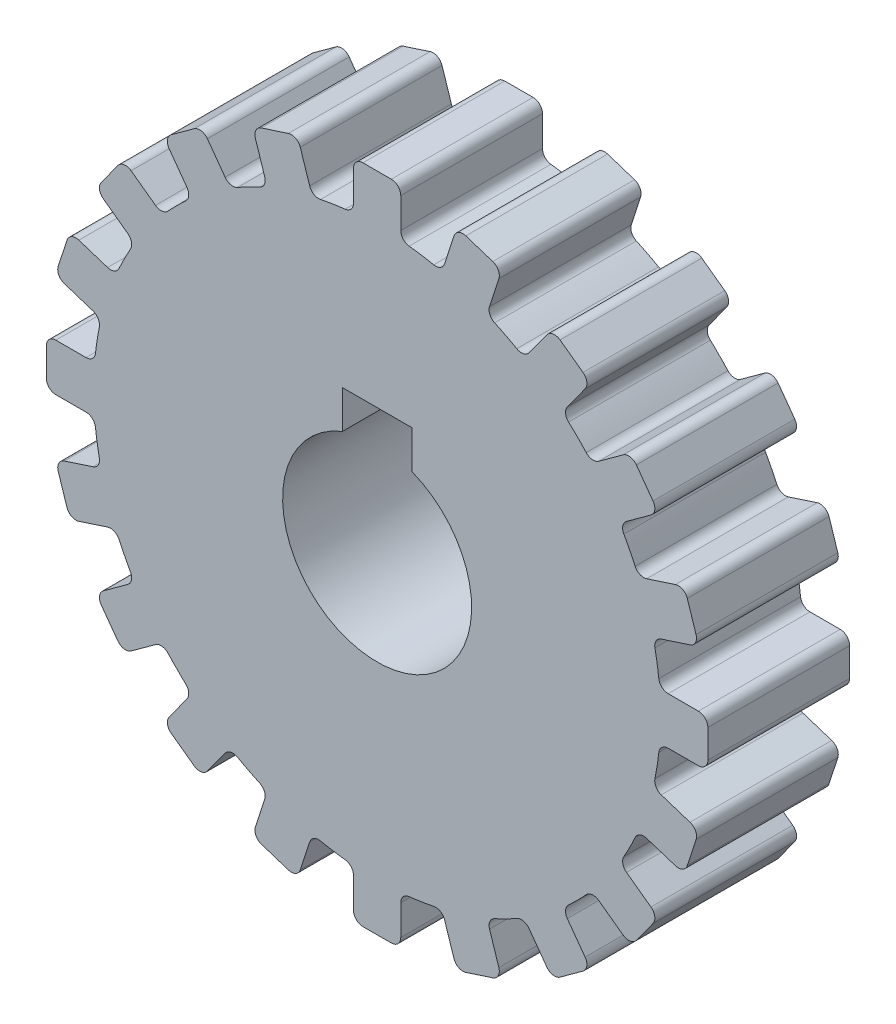
from build123d import *

# Parameters (mm, degrees)
BOSS_EXTRUDE1_DEPTH = 30
CUT_EXTRUDE1_DEPTH  = 30
SKETCH3_R           = 54.321512685
SKETCH3_R_2         = 20
CUT_EXTRUDE2_DEPTH  = 15
FILLET2_R           = 1
BOSS_EXTRUDE2_DEPTH = 15
CUT_EXTRUDE3_DEPTH  = 45
SKETCH6_R           = 95.551484503
CUT_EXTRUDE4_DEPTH  = 30


with BuildPart() as part:
    # Sketch1 → Boss-Extrude1 (new body)
    with BuildSketch(Plane.XY):
        with BuildLine():
            Line((8.324757236, 68.541581664), (7.840926028, 65.486791638))
            ThreePointArc((7.840926028, 65.486791638), (7.462274894, 64.85008445), (6.749400752, 64.648631768))
            ThreePointArc((6.749400752, 64.648631768), (5.099841222, 64.799626693), (3.446969697, 64.908538729))
            ThreePointArc((3.446969697, 64.908538729), (2.774386362, 65.219029279), (2.5, 65.907131632))
            Line((2.5, 65.907131632), (2.5, 69))
            ThreePointArc((2.5, 69), (2.207106781, 69.707106781), (1.5, 70))
            Line((1.5, 70), (-1.5, 70))
            ThreePointArc((-1.5, 70), (-2.207106781, 69.707106781), (-2.5, 69))
            Line((-2.5, 69), (-2.5, 65.907131632))
            ThreePointArc((-2.5, 65.907131632), (-2.774386362, 65.219029279), (-3.446969697, 64.908538729))
            ThreePointArc((-3.446969697, 64.908538729), (-5.099841222, 64.799626693), (-6.749400753, 64.648631768))
            ThreePointArc((-6.749400753, 64.648631768), (-7.462274894, 64.85008445), (-7.840926028, 65.486791638))
            Line((-7.840926028, 65.486791638), (-8.324757236, 68.541581664))
            ThreePointArc((-8.324757236, 68.541581664), (-8.724660325, 69.194164193), (-9.468880042, 69.372835539))
            Line((-9.468880042, 69.372835539), (-12.431945064, 68.903532144))
            ThreePointArc((-12.431945064, 68.903532144), (-13.084527593, 68.503629056), (-13.263198939, 67.759409339))
            Line((-13.263198939, 67.759409339), (-12.779367731, 64.704619313))
            ThreePointArc((-12.779367731, 64.704619313), (-12.942733018, 63.982065158), (-13.558464313, 63.570182047))
            ThreePointArc((-13.558464313, 63.570182047), (-15.173948651, 63.204044826), (-16.779578555, 62.796860937))
            ThreePointArc((-16.779578555, 62.796860937), (-17.515190176, 62.884315317), (-17.988782434, 63.453949495))
            Line((-17.988782434, 63.453949495), (-18.944531321, 66.39544211))
            ThreePointArc((-18.944531321, 66.39544211), (-19.441597338, 66.97743164), (-20.204604832, 67.037481632))
            Line((-20.204604832, 67.037481632), (-23.057774381, 66.110430649))
            ThreePointArc((-23.057774381, 66.110430649), (-23.639763911, 65.613364633), (-23.699813903, 64.850357138))
            Line((-23.699813903, 64.850357138), (-22.744065016, 61.908864523))
            ThreePointArc((-22.744065016, 61.908864523), (-22.792386632, 61.169650248), (-23.336104539, 60.666516506))
            ThreePointArc((-23.336104539, 60.666516506), (-24.874423104, 60.052169613), (-26.396587446, 59.398822978))
            ThreePointArc((-26.396587446, 59.398822978), (-27.136823346, 59.37012564), (-27.693695316, 59.858660524))
            Line((-27.693695316, 59.858660524), (-29.097828172, 62.614426418))
            ThreePointArc((-29.097828172, 62.614426418), (-29.679817701, 63.111492435), (-30.442825196, 63.051442443))
            Line((-30.442825196, 63.051442443), (-33.115844768, 61.689470944))
            ThreePointArc((-33.115844768, 61.689470944), (-33.612910785, 61.107481414), (-33.552860793, 60.34447392))
            Line((-33.552860793, 60.34447392), (-32.148727937, 57.588708026))
            ThreePointArc((-32.148727937, 57.588708026), (-32.080816044, 56.851035538), (-32.539132424, 56.269039988))
            ThreePointArc((-32.539132424, 56.269039988), (-33.962406707, 55.421610683), (-35.363624749, 54.538188865))
            ThreePointArc((-35.363624749, 54.538188865), (-36.090257863, 54.394046431), (-36.716697508, 54.789452672))
            Line((-36.716697508, 54.789452672), (-38.534639922, 57.291635743))
            ThreePointArc((-38.534639922, 57.291635743), (-39.187222452, 57.691538831), (-39.931442169, 57.512867485))
            Line((-39.931442169, 57.512867485), (-42.358493152, 55.749511728))
            ThreePointArc((-42.358493152, 55.749511728), (-42.75839624, 55.096929199), (-42.579724894, 54.352709481))
            Line((-42.579724894, 54.352709481), (-40.76178248, 51.85052641))
            ThreePointArc((-40.76178248, 51.85052641), (-40.579309295, 51.132559656), (-40.940938877, 50.486032959))
            ThreePointArc((-40.940938877, 50.486032959), (-42.214123142, 49.426387764), (-43.459892245, 48.334643539))
            ThreePointArc((-43.459892245, 48.334643539), (-44.155030455, 48.078605276), (-44.835612753, 48.371146659))
            Line((-44.835612753, 48.371146659), (-47.022600949, 50.558134855))
            ThreePointArc((-47.022600949, 50.558134855), (-47.72970773, 50.851028074), (-48.436814511, 50.558134855))
            Line((-48.436814511, 50.558134855), (-50.558134855, 48.436814511))
            ThreePointArc((-50.558134855, 48.436814511), (-50.851028074, 47.72970773), (-50.558134855, 47.022600949))
            Line((-50.558134855, 47.022600949), (-48.371146659, 44.835612753))
            ThreePointArc((-48.371146659, 44.835612753), (-48.078605276, 44.155030455), (-48.334643539, 43.459892245))
            ThreePointArc((-48.334643539, 43.459892245), (-49.426387764, 42.214123141), (-50.486032959, 40.940938877))
            ThreePointArc((-50.486032959, 40.940938877), (-51.132559656, 40.579309295), (-51.85052641, 40.76178248))
            Line((-51.85052641, 40.76178248), (-54.352709481, 42.579724894))
            ThreePointArc((-54.352709481, 42.579724894), (-55.096929199, 42.75839624), (-55.749511728, 42.358493152))
            Line((-55.749511728, 42.358493152), (-57.512867485, 39.931442169))
            ThreePointArc((-57.512867485, 39.931442169), (-57.691538831, 39.187222452), (-57.291635743, 38.534639922))
            Line((-57.291635743, 38.534639922), (-54.789452672, 36.716697508))
            ThreePointArc((-54.789452672, 36.716697508), (-54.394046431, 36.090257863), (-54.538188865, 35.363624749))
            ThreePointArc((-54.538188865, 35.363624749), (-55.421610683, 33.962406707), (-56.269039988, 32.539132424))
            ThreePointArc((-56.269039988, 32.539132424), (-56.851035538, 32.080816044), (-57.588708026, 32.148727937))
            Line((-57.588708026, 32.148727937), (-60.34447392, 33.552860793))
            ThreePointArc((-60.34447392, 33.552860793), (-61.107481414, 33.612910785), (-61.689470944, 33.115844768))
            Line((-61.689470944, 33.115844768), (-63.051442443, 30.442825196))
            ThreePointArc((-63.051442443, 30.442825196), (-63.111492435, 29.679817701), (-62.614426418, 29.097828172))
            Line((-62.614426418, 29.097828172), (-59.858660524, 27.693695316))
            ThreePointArc((-59.858660524, 27.693695316), (-59.37012564, 27.136823346), (-59.398822978, 26.396587446))
            ThreePointArc((-59.398822978, 26.396587446), (-60.052169613, 24.874423104), (-60.666516506, 23.336104539))
            ThreePointArc((-60.666516506, 23.336104539), (-61.169650248, 22.792386632), (-61.908864523, 22.744065016))
            Line((-61.908864523, 22.744065016), (-64.850357138, 23.699813903))
            ThreePointArc((-64.850357138, 23.699813903), (-65.613364633, 23.639763911), (-66.110430649, 23.057774381))
            Line((-66.110430649, 23.057774381), (-67.037481632, 20.204604832))
            ThreePointArc((-67.037481632, 20.204604832), (-66.97743164, 19.441597338), (-66.39544211, 18.944531321))
            Line((-66.39544211, 18.944531321), (-63.453949495, 17.988782434))
            ThreePointArc((-63.453949495, 17.988782434), (-62.884315317, 17.515190176), (-62.796860937, 16.779578555))
            ThreePointArc((-62.796860937, 16.779578555), (-63.204044826, 15.173948651), (-63.570182047, 13.558464313))
            ThreePointArc((-63.570182047, 13.558464313), (-63.982065158, 12.942733018), (-64.704619313, 12.779367731))
            Line((-64.704619313, 12.779367731), (-67.759409339, 13.263198939))
            ThreePointArc((-67.759409339, 13.263198939), (-68.503629056, 13.084527593), (-68.903532144, 12.431945064))
            Line((-68.903532144, 12.431945064), (-69.372835539, 9.468880042))
            ThreePointArc((-69.372835539, 9.468880042), (-69.194164193, 8.724660325), (-68.541581664, 8.324757236))
            Line((-68.541581664, 8.324757236), (-65.486791638, 7.840926028))
            ThreePointArc((-65.486791638, 7.840926028), (-64.85008445, 7.462274894), (-64.648631768, 6.749400752))
            ThreePointArc((-64.648631768, 6.749400752), (-64.799626693, 5.099841222), (-64.908538729, 3.446969697))
            ThreePointArc((-64.908538729, 3.446969697), (-65.219029279, 2.774386362), (-65.907131632, 2.5))
            Line((-65.907131632, 2.5), (-69, 2.5))
            ThreePointArc((-69, 2.5), (-69.707106781, 2.207106781), (-70, 1.5))
            Line((-70, 1.5), (-70, -1.5))
            ThreePointArc((-70, -1.5), (-69.707106781, -2.207106781), (-69, -2.5))
            Line((-69, -2.5), (-65.907131632, -2.5))
            ThreePointArc((-65.907131632, -2.5), (-65.219029279, -2.774386362), (-64.908538729, -3.446969697))
            ThreePointArc((-64.908538729, -3.446969697), (-64.799626693, -5.099841222), (-64.648631768, -6.749400753))
            ThreePointArc((-64.648631768, -6.749400753), (-64.85008445, -7.462274894), (-65.486791638, -7.840926028))
            Line((-65.486791638, -7.840926028), (-68.541581664, -8.324757236))
            ThreePointArc((-68.541581664, -8.324757236), (-69.194164193, -8.724660325), (-69.372835539, -9.468880042))
            Line((-69.372835539, -9.468880042), (-68.903532144, -12.431945064))
            ThreePointArc((-68.903532144, -12.431945064), (-68.503629056, -13.084527593), (-67.759409339, -13.263198939))
            Line((-67.759409339, -13.263198939), (-64.704619313, -12.779367731))
            ThreePointArc((-64.704619313, -12.779367731), (-63.982065158, -12.942733018), (-63.570182047, -13.558464313))
            ThreePointArc((-63.570182047, -13.558464313), (-63.204044826, -15.173948651), (-62.796860937, -16.779578555))
            ThreePointArc((-62.796860937, -16.779578555), (-62.884315317, -17.515190176), (-63.453949495, -17.988782434))
            Line((-63.453949495, -17.988782434), (-66.39544211, -18.944531321))
            ThreePointArc((-66.39544211, -18.944531321), (-66.97743164, -19.441597338), (-67.037481632, -20.204604832))
            Line((-67.037481632, -20.204604832), (-66.110430649, -23.057774381))
            ThreePointArc((-66.110430649, -23.057774381), (-65.613364633, -23.639763911), (-64.850357138, -23.699813903))
            Line((-64.850357138, -23.699813903), (-61.908864523, -22.744065016))
            ThreePointArc((-61.908864523, -22.744065016), (-61.169650248, -22.792386632), (-60.666516506, -23.336104539))
            ThreePointArc((-60.666516506, -23.336104539), (-60.052169613, -24.874423104), (-59.398822978, -26.396587446))
            ThreePointArc((-59.398822978, -26.396587446), (-59.37012564, -27.136823346), (-59.858660524, -27.693695316))
            Line((-59.858660524, -27.693695316), (-62.614426418, -29.097828172))
            ThreePointArc((-62.614426418, -29.097828172), (-63.111492435, -29.679817701), (-63.051442443, -30.442825196))
            Line((-63.051442443, -30.442825196), (-61.689470944, -33.115844768))
            ThreePointArc((-61.689470944, -33.115844768), (-61.107481414, -33.612910785), (-60.34447392, -33.552860793))
            Line((-60.34447392, -33.552860793), (-57.588708026, -32.148727937))
            ThreePointArc((-57.588708026, -32.148727937), (-56.851035538, -32.080816044), (-56.269039988, -32.539132424))
            ThreePointArc((-56.269039988, -32.539132424), (-55.421610683, -33.962406707), (-54.538188865, -35.363624749))
            ThreePointArc((-54.538188865, -35.363624749), (-54.394046431, -36.090257863), (-54.789452672, -36.716697508))
            Line((-54.789452672, -36.716697508), (-57.291635743, -38.534639922))
            ThreePointArc((-57.291635743, -38.534639922), (-57.691538831, -39.187222452), (-57.512867485, -39.931442169))
            Line((-57.512867485, -39.931442169), (-55.749511728, -42.358493152))
            ThreePointArc((-55.749511728, -42.358493152), (-55.096929199, -42.75839624), (-54.352709481, -42.579724894))
            Line((-54.352709481, -42.579724894), (-51.85052641, -40.76178248))
            ThreePointArc((-51.85052641, -40.76178248), (-51.132559656, -40.579309295), (-50.486032959, -40.940938877))
            ThreePointArc((-50.486032959, -40.940938877), (-49.426387764, -42.214123142), (-48.334643539, -43.459892245))
            ThreePointArc((-48.334643539, -43.459892245), (-48.078605276, -44.155030455), (-48.371146659, -44.835612753))
            Line((-48.371146659, -44.835612753), (-50.558134855, -47.022600949))
            ThreePointArc((-50.558134855, -47.022600949), (-50.851028074, -47.72970773), (-50.558134855, -48.436814511))
            Line((-50.558134855, -48.436814511), (-48.436814511, -50.558134855))
            ThreePointArc((-48.436814511, -50.558134855), (-47.72970773, -50.851028074), (-47.022600949, -50.558134855))
            Line((-47.022600949, -50.558134855), (-44.835612753, -48.371146659))
            ThreePointArc((-44.835612753, -48.371146659), (-44.155030455, -48.078605276), (-43.459892245, -48.334643539))
            ThreePointArc((-43.459892245, -48.334643539), (-42.214123141, -49.426387764), (-40.940938877, -50.486032959))
            ThreePointArc((-40.940938877, -50.486032959), (-40.579309295, -51.132559656), (-40.76178248, -51.85052641))
            Line((-40.76178248, -51.85052641), (-42.579724894, -54.352709481))
            ThreePointArc((-42.579724894, -54.352709481), (-42.75839624, -55.096929199), (-42.358493152, -55.749511728))
            Line((-42.358493152, -55.749511728), (-39.931442169, -57.512867485))
            ThreePointArc((-39.931442169, -57.512867485), (-39.187222452, -57.691538831), (-38.534639922, -57.291635743))
            Line((-38.534639922, -57.291635743), (-36.716697508, -54.789452672))
            ThreePointArc((-36.716697508, -54.789452672), (-36.090257863, -54.394046431), (-35.363624749, -54.538188865))
            ThreePointArc((-35.363624749, -54.538188865), (-33.962406707, -55.421610683), (-32.539132424, -56.269039988))
            ThreePointArc((-32.539132424, -56.269039988), (-32.080816044, -56.851035538), (-32.148727937, -57.588708026))
            Line((-32.148727937, -57.588708026), (-33.552860793, -60.34447392))
            ThreePointArc((-33.552860793, -60.34447392), (-33.612910785, -61.107481414), (-33.115844768, -61.689470944))
            Line((-33.115844768, -61.689470944), (-30.442825196, -63.051442443))
            ThreePointArc((-30.442825196, -63.051442443), (-29.679817701, -63.111492435), (-29.097828172, -62.614426418))
            Line((-29.097828172, -62.614426418), (-27.693695316, -59.858660524))
            ThreePointArc((-27.693695316, -59.858660524), (-27.136823346, -59.37012564), (-26.396587446, -59.398822978))
            ThreePointArc((-26.396587446, -59.398822978), (-24.874423104, -60.052169613), (-23.336104539, -60.666516506))
            ThreePointArc((-23.336104539, -60.666516506), (-22.792386632, -61.169650248), (-22.744065016, -61.908864523))
            Line((-22.744065016, -61.908864523), (-23.699813903, -64.850357138))
            ThreePointArc((-23.699813903, -64.850357138), (-23.639763911, -65.613364633), (-23.057774381, -66.110430649))
            Line((-23.057774381, -66.110430649), (-20.204604832, -67.037481632))
            ThreePointArc((-20.204604832, -67.037481632), (-19.441597338, -66.97743164), (-18.944531321, -66.39544211))
            Line((-18.944531321, -66.39544211), (-17.988782434, -63.453949495))
            ThreePointArc((-17.988782434, -63.453949495), (-17.515190176, -62.884315317), (-16.779578555, -62.796860937))
            ThreePointArc((-16.779578555, -62.796860937), (-15.173948651, -63.204044826), (-13.558464313, -63.570182047))
            ThreePointArc((-13.558464313, -63.570182047), (-12.942733018, -63.982065158), (-12.779367731, -64.704619313))
            Line((-12.779367731, -64.704619313), (-13.263198939, -67.759409339))
            ThreePointArc((-13.263198939, -67.759409339), (-13.084527593, -68.503629056), (-12.431945064, -68.903532144))
            Line((-12.431945064, -68.903532144), (-9.468880042, -69.372835539))
            ThreePointArc((-9.468880042, -69.372835539), (-8.724660325, -69.194164193), (-8.324757236, -68.541581664))
            Line((-8.324757236, -68.541581664), (-7.840926028, -65.486791638))
            ThreePointArc((-7.840926028, -65.486791638), (-7.462274894, -64.85008445), (-6.749400752, -64.648631768))
            ThreePointArc((-6.749400752, -64.648631768), (-5.099841222, -64.799626693), (-3.446969697, -64.908538729))
            ThreePointArc((-3.446969697, -64.908538729), (-2.774386362, -65.219029279), (-2.5, -65.907131632))
            Line((-2.5, -65.907131632), (-2.5, -69))
            ThreePointArc((-2.5, -69), (-2.207106781, -69.707106781), (-1.5, -70))
            Line((-1.5, -70), (1.5, -70))
            ThreePointArc((1.5, -70), (2.207106781, -69.707106781), (2.5, -69))
            Line((2.5, -69), (2.5, -65.907131632))
            ThreePointArc((2.5, -65.907131632), (2.774386362, -65.219029279), (3.446969697, -64.908538729))
            ThreePointArc((3.446969697, -64.908538729), (5.099841222, -64.799626693), (6.749400753, -64.648631768))
            ThreePointArc((6.749400753, -64.648631768), (7.462274894, -64.85008445), (7.840926028, -65.486791638))
            Line((7.840926028, -65.486791638), (8.324757236, -68.541581664))
            ThreePointArc((8.324757236, -68.541581664), (8.724660325, -69.194164193), (9.468880042, -69.372835539))
            Line((9.468880042, -69.372835539), (12.431945064, -68.903532144))
            ThreePointArc((12.431945064, -68.903532144), (13.084527593, -68.503629056), (13.263198939, -67.759409339))
            Line((13.263198939, -67.759409339), (12.779367731, -64.704619313))
            ThreePointArc((12.779367731, -64.704619313), (12.942733018, -63.982065158), (13.558464313, -63.570182047))
            ThreePointArc((13.558464313, -63.570182047), (15.173948651, -63.204044826), (16.779578555, -62.796860937))
            ThreePointArc((16.779578555, -62.796860937), (17.515190176, -62.884315317), (17.988782434, -63.453949495))
            Line((17.988782434, -63.453949495), (18.944531321, -66.39544211))
            ThreePointArc((18.944531321, -66.39544211), (19.441597338, -66.97743164), (20.204604832, -67.037481632))
            Line((20.204604832, -67.037481632), (23.057774381, -66.110430649))
            ThreePointArc((23.057774381, -66.110430649), (23.639763911, -65.613364633), (23.699813903, -64.850357138))
            Line((23.699813903, -64.850357138), (22.744065016, -61.908864523))
            ThreePointArc((22.744065016, -61.908864523), (22.792386632, -61.169650248), (23.336104539, -60.666516506))
            ThreePointArc((23.336104539, -60.666516506), (24.874423104, -60.052169613), (26.396587446, -59.398822978))
            ThreePointArc((26.396587446, -59.398822978), (27.136823346, -59.37012564), (27.693695316, -59.858660524))
            Line((27.693695316, -59.858660524), (29.097828172, -62.614426418))
            ThreePointArc((29.097828172, -62.614426418), (29.679817701, -63.111492435), (30.442825196, -63.051442443))
            Line((30.442825196, -63.051442443), (33.115844768, -61.689470944))
            ThreePointArc((33.115844768, -61.689470944), (33.612910785, -61.107481414), (33.552860793, -60.34447392))
            Line((33.552860793, -60.34447392), (32.148727937, -57.588708026))
            ThreePointArc((32.148727937, -57.588708026), (32.080816044, -56.851035538), (32.539132424, -56.269039988))
            ThreePointArc((32.539132424, -56.269039988), (33.962406707, -55.421610683), (35.363624749, -54.538188865))
            ThreePointArc((35.363624749, -54.538188865), (36.090257863, -54.394046431), (36.716697508, -54.789452672))
            Line((36.716697508, -54.789452672), (38.534639922, -57.291635743))
            ThreePointArc((38.534639922, -57.291635743), (39.187222452, -57.691538831), (39.931442169, -57.512867485))
            Line((39.931442169, -57.512867485), (42.358493152, -55.749511728))
            ThreePointArc((42.358493152, -55.749511728), (42.75839624, -55.096929199), (42.579724894, -54.352709481))
            Line((42.579724894, -54.352709481), (40.76178248, -51.85052641))
            ThreePointArc((40.76178248, -51.85052641), (40.579309295, -51.132559656), (40.940938877, -50.486032959))
            ThreePointArc((40.940938877, -50.486032959), (42.214123142, -49.426387764), (43.459892245, -48.334643539))
            ThreePointArc((43.459892245, -48.334643539), (44.155030455, -48.078605276), (44.835612753, -48.371146659))
            Line((44.835612753, -48.371146659), (47.022600949, -50.558134855))
            ThreePointArc((47.022600949, -50.558134855), (47.72970773, -50.851028074), (48.436814511, -50.558134855))
            Line((48.436814511, -50.558134855), (50.558134855, -48.436814511))
            ThreePointArc((50.558134855, -48.436814511), (50.851028074, -47.72970773), (50.558134855, -47.022600949))
            Line((50.558134855, -47.022600949), (48.371146659, -44.835612753))
            ThreePointArc((48.371146659, -44.835612753), (48.078605276, -44.155030455), (48.334643539, -43.459892245))
            ThreePointArc((48.334643539, -43.459892245), (49.426387764, -42.214123141), (50.486032959, -40.940938877))
            ThreePointArc((50.486032959, -40.940938877), (51.132559656, -40.579309295), (51.85052641, -40.76178248))
            Line((51.85052641, -40.76178248), (54.352709481, -42.579724894))
            ThreePointArc((54.352709481, -42.579724894), (55.096929199, -42.75839624), (55.749511728, -42.358493152))
            Line((55.749511728, -42.358493152), (57.512867485, -39.931442169))
            ThreePointArc((57.512867485, -39.931442169), (57.691538831, -39.187222452), (57.291635743, -38.534639922))
            Line((57.291635743, -38.534639922), (54.789452672, -36.716697508))
            ThreePointArc((54.789452672, -36.716697508), (54.394046431, -36.090257863), (54.538188865, -35.363624749))
            ThreePointArc((54.538188865, -35.363624749), (55.421610683, -33.962406707), (56.269039988, -32.539132424))
            ThreePointArc((56.269039988, -32.539132424), (56.851035538, -32.080816044), (57.588708026, -32.148727937))
            Line((57.588708026, -32.148727937), (60.34447392, -33.552860793))
            ThreePointArc((60.34447392, -33.552860793), (61.107481414, -33.612910785), (61.689470944, -33.115844768))
            Line((61.689470944, -33.115844768), (63.051442443, -30.442825196))
            ThreePointArc((63.051442443, -30.442825196), (63.111492435, -29.679817701), (62.614426418, -29.097828172))
            Line((62.614426418, -29.097828172), (59.858660524, -27.693695316))
            ThreePointArc((59.858660524, -27.693695316), (59.37012564, -27.136823346), (59.398822978, -26.396587446))
            ThreePointArc((59.398822978, -26.396587446), (60.052169613, -24.874423104), (60.666516506, -23.336104539))
            ThreePointArc((60.666516506, -23.336104539), (61.169650248, -22.792386632), (61.908864523, -22.744065016))
            Line((61.908864523, -22.744065016), (64.850357138, -23.699813903))
            ThreePointArc((64.850357138, -23.699813903), (65.613364633, -23.639763911), (66.110430649, -23.057774381))
            Line((66.110430649, -23.057774381), (67.037481632, -20.204604832))
            ThreePointArc((67.037481632, -20.204604832), (66.97743164, -19.441597338), (66.39544211, -18.944531321))
            Line((66.39544211, -18.944531321), (63.453949495, -17.988782434))
            ThreePointArc((63.453949495, -17.988782434), (62.884315317, -17.515190176), (62.796860937, -16.779578555))
            ThreePointArc((62.796860937, -16.779578555), (63.204044826, -15.173948651), (63.570182047, -13.558464313))
            ThreePointArc((63.570182047, -13.558464313), (63.982065158, -12.942733018), (64.704619313, -12.779367731))
            Line((64.704619313, -12.779367731), (67.759409339, -13.263198939))
            ThreePointArc((67.759409339, -13.263198939), (68.503629056, -13.084527593), (68.903532144, -12.431945064))
            Line((68.903532144, -12.431945064), (69.372835539, -9.468880042))
            ThreePointArc((69.372835539, -9.468880042), (69.194164193, -8.724660325), (68.541581664, -8.324757236))
            Line((68.541581664, -8.324757236), (65.486791638, -7.840926028))
            ThreePointArc((65.486791638, -7.840926028), (64.85008445, -7.462274894), (64.648631768, -6.749400752))
            ThreePointArc((64.648631768, -6.749400752), (64.799626693, -5.099841222), (64.908538729, -3.446969697))
            ThreePointArc((64.908538729, -3.446969697), (65.219029279, -2.774386362), (65.907131632, -2.5))
            Line((65.907131632, -2.5), (69, -2.5))
            ThreePointArc((69, -2.5), (69.707106781, -2.207106781), (70, -1.5))
            Line((70, -1.5), (70, 1.5))
            ThreePointArc((70, 1.5), (69.707106781, 2.207106781), (69, 2.5))
            Line((69, 2.5), (65.907131632, 2.5))
            ThreePointArc((65.907131632, 2.5), (65.219029279, 2.774386362), (64.908538729, 3.446969697))
            ThreePointArc((64.908538729, 3.446969697), (64.799626693, 5.099841222), (64.648631768, 6.749400753))
            ThreePointArc((64.648631768, 6.749400753), (64.85008445, 7.462274894), (65.486791638, 7.840926028))
            Line((65.486791638, 7.840926028), (68.541581664, 8.324757236))
            ThreePointArc((68.541581664, 8.324757236), (69.194164193, 8.724660325), (69.372835539, 9.468880042))
            Line((69.372835539, 9.468880042), (68.903532144, 12.431945064))
            ThreePointArc((68.903532144, 12.431945064), (68.503629056, 13.084527593), (67.759409339, 13.263198939))
            Line((67.759409339, 13.263198939), (64.704619313, 12.779367731))
            ThreePointArc((64.704619313, 12.779367731), (63.982065158, 12.942733018), (63.570182047, 13.558464313))
            ThreePointArc((63.570182047, 13.558464313), (63.204044826, 15.173948651), (62.796860937, 16.779578555))
            ThreePointArc((62.796860937, 16.779578555), (62.884315317, 17.515190176), (63.453949495, 17.988782434))
            Line((63.453949495, 17.988782434), (66.39544211, 18.944531321))
            ThreePointArc((66.39544211, 18.944531321), (66.97743164, 19.441597338), (67.037481632, 20.204604832))
            Line((67.037481632, 20.204604832), (66.110430649, 23.057774381))
            ThreePointArc((66.110430649, 23.057774381), (65.613364633, 23.639763911), (64.850357138, 23.699813903))
            Line((64.850357138, 23.699813903), (61.908864523, 22.744065016))
            ThreePointArc((61.908864523, 22.744065016), (61.169650248, 22.792386632), (60.666516506, 23.336104539))
            ThreePointArc((60.666516506, 23.336104539), (60.052169613, 24.874423104), (59.398822978, 26.396587446))
            ThreePointArc((59.398822978, 26.396587446), (59.37012564, 27.136823346), (59.858660524, 27.693695316))
            Line((59.858660524, 27.693695316), (62.614426418, 29.097828172))
            ThreePointArc((62.614426418, 29.097828172), (63.111492435, 29.679817701), (63.051442443, 30.442825196))
            Line((63.051442443, 30.442825196), (61.689470944, 33.115844768))
            ThreePointArc((61.689470944, 33.115844768), (61.107481414, 33.612910785), (60.34447392, 33.552860793))
            Line((60.34447392, 33.552860793), (57.588708026, 32.148727937))
            ThreePointArc((57.588708026, 32.148727937), (56.851035538, 32.080816044), (56.269039988, 32.539132424))
            ThreePointArc((56.269039988, 32.539132424), (55.421610683, 33.962406707), (54.538188865, 35.363624749))
            ThreePointArc((54.538188865, 35.363624749), (54.394046431, 36.090257863), (54.789452672, 36.716697508))
            Line((54.789452672, 36.716697508), (57.291635743, 38.534639922))
            ThreePointArc((57.291635743, 38.534639922), (57.691538831, 39.187222452), (57.512867485, 39.931442169))
            Line((57.512867485, 39.931442169), (55.749511728, 42.358493152))
            ThreePointArc((55.749511728, 42.358493152), (55.096929199, 42.75839624), (54.352709481, 42.579724894))
            Line((54.352709481, 42.579724894), (51.85052641, 40.76178248))
            ThreePointArc((51.85052641, 40.76178248), (51.132559656, 40.579309295), (50.486032959, 40.940938877))
            ThreePointArc((50.486032959, 40.940938877), (49.426387764, 42.214123142), (48.334643539, 43.459892245))
            ThreePointArc((48.334643539, 43.459892245), (48.078605276, 44.155030455), (48.371146659, 44.835612753))
            Line((48.371146659, 44.835612753), (50.558134855, 47.022600949))
            ThreePointArc((50.558134855, 47.022600949), (50.851028074, 47.72970773), (50.558134855, 48.436814511))
            Line((50.558134855, 48.436814511), (48.436814511, 50.558134855))
            ThreePointArc((48.436814511, 50.558134855), (47.72970773, 50.851028074), (47.022600949, 50.558134855))
            Line((47.022600949, 50.558134855), (44.835612753, 48.371146659))
            ThreePointArc((44.835612753, 48.371146659), (44.155030455, 48.078605276), (43.459892245, 48.334643539))
            ThreePointArc((43.459892245, 48.334643539), (42.214123141, 49.426387764), (40.940938877, 50.486032959))
            ThreePointArc((40.940938877, 50.486032959), (40.579309295, 51.132559656), (40.76178248, 51.85052641))
            Line((40.76178248, 51.85052641), (42.579724894, 54.352709481))
            ThreePointArc((42.579724894, 54.352709481), (42.75839624, 55.096929199), (42.358493152, 55.749511728))
            Line((42.358493152, 55.749511728), (39.931442169, 57.512867485))
            ThreePointArc((39.931442169, 57.512867485), (39.187222452, 57.691538831), (38.534639922, 57.291635743))
            Line((38.534639922, 57.291635743), (36.716697508, 54.789452672))
            ThreePointArc((36.716697508, 54.789452672), (36.090257863, 54.394046431), (35.363624749, 54.538188865))
            ThreePointArc((35.363624749, 54.538188865), (33.962406707, 55.421610683), (32.539132424, 56.269039988))
            ThreePointArc((32.539132424, 56.269039988), (32.080816044, 56.851035538), (32.148727937, 57.588708026))
            Line((32.148727937, 57.588708026), (33.552860793, 60.34447392))
            ThreePointArc((33.552860793, 60.34447392), (33.612910785, 61.107481414), (33.115844768, 61.689470944))
            Line((33.115844768, 61.689470944), (30.442825196, 63.051442443))
            ThreePointArc((30.442825196, 63.051442443), (29.679817701, 63.111492435), (29.097828172, 62.614426418))
            Line((29.097828172, 62.614426418), (27.693695316, 59.858660524))
            ThreePointArc((27.693695316, 59.858660524), (27.136823346, 59.37012564), (26.396587446, 59.398822978))
            ThreePointArc((26.396587446, 59.398822978), (24.874423104, 60.052169613), (23.336104539, 60.666516506))
            ThreePointArc((23.336104539, 60.666516506), (22.792386632, 61.169650248), (22.744065016, 61.908864523))
            Line((22.744065016, 61.908864523), (23.699813903, 64.850357138))
            ThreePointArc((23.699813903, 64.850357138), (23.639763911, 65.613364633), (23.057774381, 66.110430649))
            Line((23.057774381, 66.110430649), (20.204604832, 67.037481632))
            ThreePointArc((20.204604832, 67.037481632), (19.441597338, 66.97743164), (18.944531321, 66.39544211))
            Line((18.944531321, 66.39544211), (17.988782434, 63.453949495))
            ThreePointArc((17.988782434, 63.453949495), (17.515190176, 62.884315317), (16.779578555, 62.796860937))
            ThreePointArc((16.779578555, 62.796860937), (15.173948651, 63.204044826), (13.558464313, 63.570182047))
            ThreePointArc((13.558464313, 63.570182047), (12.942733018, 63.982065158), (12.779367731, 64.704619313))
            Line((12.779367731, 64.704619313), (13.263198939, 67.759409339))
            ThreePointArc((13.263198939, 67.759409339), (13.084527593, 68.503629056), (12.431945064, 68.903532144))
            Line((12.431945064, 68.903532144), (9.468880042, 69.372835539))
            ThreePointArc((9.468880042, 69.372835539), (8.724660325, 69.194164193), (8.324757236, 68.541581664))
        make_face()
    extrude(amount=BOSS_EXTRUDE1_DEPTH)

    # Sketch2 → Cut-Extrude1 (cut)
    with BuildSketch(Plane.XY.offset(30)):
        with BuildLine():
            Line((-3.538659763, 13.11467819), (3.538659763, 13.11467819))
            Line((3.538659763, 13.11467819), (3.538659763, 9.352961407))
            ThreePointArc((3.538659763, 9.352961407), (0, -10), (-3.538659763, 9.352961407))
            Line((-3.538659763, 9.352961407), (-3.538659763, 13.11467819))
        make_face()
    extrude(amount=-CUT_EXTRUDE1_DEPTH, mode=Mode.SUBTRACT)

    # Sketch3 → Cut-Extrude2 (cut)
    with BuildSketch(Plane.XY.offset(30)):
        Circle(SKETCH3_R)
        Circle(SKETCH3_R_2, mode=Mode.SUBTRACT)
    extrude(amount=-CUT_EXTRUDE2_DEPTH, mode=Mode.SUBTRACT)

    # Fillet2
    fillet2_edges = [part.edges().sort_by_distance(p)[0] for p in [
        (-54.321512685, 0, 30),
    ]]
    fillet(fillet2_edges, radius=FILLET2_R)

    # Sketch4 → Boss-Extrude2 (add)
    with BuildSketch(Plane.XY.offset(30)):
        with BuildLine():
            Line((8.128936518, 33.10846404), (7.140633936, 30.066781454))
            ThreePointArc((7.140633936, 30.066781454), (6.693220985, 29.511886902), (5.989913632, 29.395933982))
            ThreePointArc((5.989913632, 29.395933982), (4.693033951, 29.630650218), (3.387096774, 29.808179673))
            ThreePointArc((3.387096774, 29.808179673), (2.754043156, 30.135791378), (2.5, 30.801785663))
            Line((2.5, 30.801785663), (2.5, 34))
            ThreePointArc((2.5, 34), (2.207106781, 34.707106781), (1.5, 35))
            Line((1.5, 35), (-1.5, 35))
            ThreePointArc((-1.5, 35), (-2.207106781, 34.707106781), (-2.5, 34))
            Line((-2.5, 34), (-2.5, 30.801785663))
            ThreePointArc((-2.5, 30.801785663), (-2.754043156, 30.135791378), (-3.387096774, 29.808179673))
            ThreePointArc((-3.387096774, 29.808179673), (-4.693033951, 29.630650218), (-5.989913632, 29.395933982))
            ThreePointArc((-5.989913632, 29.395933982), (-6.693220985, 29.511886902), (-7.140633936, 30.066781454))
            Line((-7.140633936, 30.066781454), (-8.128936518, 33.10846404))
            ThreePointArc((-8.128936518, 33.10846404), (-8.626002535, 33.69045357), (-9.389010029, 33.750503562))
            Line((-9.389010029, 33.750503562), (-12.242179578, 32.823452579))
            ThreePointArc((-12.242179578, 32.823452579), (-12.824169107, 32.326386562), (-12.884219099, 31.563379068))
            Line((-12.884219099, 31.563379068), (-11.895916518, 28.521696482))
            ThreePointArc((-11.895916518, 28.521696482), (-11.931722365, 27.809794625), (-12.432554549, 27.302593052))
            ThreePointArc((-12.432554549, 27.302593052), (-13.619714992, 26.730195726), (-14.780589558, 26.106209459))
            ThreePointArc((-14.780589558, 26.106209459), (-15.485306022, 25.999153315), (-16.082292871, 26.388631189))
            Line((-16.082292871, 26.388631189), (-17.962156092, 28.976040939))
            ThreePointArc((-17.962156092, 28.976040939), (-18.614738621, 29.375944028), (-19.358958339, 29.197272682))
            Line((-19.358958339, 29.197272682), (-21.786009322, 27.433916925))
            ThreePointArc((-21.786009322, 27.433916925), (-22.18591241, 26.781334395), (-22.007241064, 26.037114678))
            Line((-22.007241064, 26.037114678), (-20.127377843, 23.449704927))
            ThreePointArc((-20.127377843, 23.449704927), (-19.941441455, 22.761581412), (-20.261027262, 22.124438395))
            ThreePointArc((-20.261027262, 22.124438395), (-21.213203436, 21.213203436), (-22.124438395, 20.261027262))
            ThreePointArc((-22.124438395, 20.261027262), (-22.761581412, 19.941441455), (-23.449704927, 20.127377843))
            Line((-23.449704927, 20.127377843), (-26.037114678, 22.007241064))
            ThreePointArc((-26.037114678, 22.007241064), (-26.781334395, 22.18591241), (-27.433916925, 21.786009322))
            Line((-27.433916925, 21.786009322), (-29.197272682, 19.358958339))
            ThreePointArc((-29.197272682, 19.358958339), (-29.375944028, 18.614738621), (-28.976040939, 17.962156092))
            Line((-28.976040939, 17.962156092), (-26.388631189, 16.082292871))
            ThreePointArc((-26.388631189, 16.082292871), (-25.999153315, 15.485306022), (-26.106209459, 14.780589558))
            ThreePointArc((-26.106209459, 14.780589558), (-26.730195726, 13.619714992), (-27.302593052, 12.432554549))
            ThreePointArc((-27.302593052, 12.432554549), (-27.809794625, 11.931722365), (-28.521696482, 11.895916518))
            Line((-28.521696482, 11.895916518), (-31.563379068, 12.884219099))
            ThreePointArc((-31.563379068, 12.884219099), (-32.326386562, 12.824169107), (-32.823452579, 12.242179578))
            Line((-32.823452579, 12.242179578), (-33.750503562, 9.389010029))
            ThreePointArc((-33.750503562, 9.389010029), (-33.69045357, 8.626002535), (-33.10846404, 8.128936518))
            Line((-33.10846404, 8.128936518), (-30.066781454, 7.140633936))
            ThreePointArc((-30.066781454, 7.140633936), (-29.511886902, 6.693220985), (-29.395933982, 5.989913632))
            ThreePointArc((-29.395933982, 5.989913632), (-29.630650218, 4.693033951), (-29.808179673, 3.387096774))
            ThreePointArc((-29.808179673, 3.387096774), (-30.135791378, 2.754043156), (-30.801785663, 2.5))
            Line((-30.801785663, 2.5), (-34, 2.5))
            ThreePointArc((-34, 2.5), (-34.707106781, 2.207106781), (-35, 1.5))
            Line((-35, 1.5), (-35, -1.5))
            ThreePointArc((-35, -1.5), (-34.707106781, -2.207106781), (-34, -2.5))
            Line((-34, -2.5), (-30.801785663, -2.5))
            ThreePointArc((-30.801785663, -2.5), (-30.135791378, -2.754043156), (-29.808179673, -3.387096774))
            ThreePointArc((-29.808179673, -3.387096774), (-29.630650218, -4.693033951), (-29.395933982, -5.989913632))
            ThreePointArc((-29.395933982, -5.989913632), (-29.511886902, -6.693220985), (-30.066781454, -7.140633936))
            Line((-30.066781454, -7.140633936), (-33.10846404, -8.128936518))
            ThreePointArc((-33.10846404, -8.128936518), (-33.69045357, -8.626002535), (-33.750503562, -9.389010029))
            Line((-33.750503562, -9.389010029), (-32.823452579, -12.242179578))
            ThreePointArc((-32.823452579, -12.242179578), (-32.326386562, -12.824169107), (-31.563379068, -12.884219099))
            Line((-31.563379068, -12.884219099), (-28.521696482, -11.895916518))
            ThreePointArc((-28.521696482, -11.895916518), (-27.809794625, -11.931722365), (-27.302593052, -12.432554549))
            ThreePointArc((-27.302593052, -12.432554549), (-26.730195726, -13.619714992), (-26.106209459, -14.780589558))
            ThreePointArc((-26.106209459, -14.780589558), (-25.999153315, -15.485306022), (-26.388631189, -16.082292871))
            Line((-26.388631189, -16.082292871), (-28.976040939, -17.962156092))
            ThreePointArc((-28.976040939, -17.962156092), (-29.375944028, -18.614738621), (-29.197272682, -19.358958339))
            Line((-29.197272682, -19.358958339), (-27.433916925, -21.786009322))
            ThreePointArc((-27.433916925, -21.786009322), (-26.781334395, -22.18591241), (-26.037114678, -22.007241064))
            Line((-26.037114678, -22.007241064), (-23.449704927, -20.127377843))
            ThreePointArc((-23.449704927, -20.127377843), (-22.761581412, -19.941441455), (-22.124438395, -20.261027262))
            ThreePointArc((-22.124438395, -20.261027262), (-21.213203436, -21.213203436), (-20.261027262, -22.124438395))
            ThreePointArc((-20.261027262, -22.124438395), (-19.941441455, -22.761581412), (-20.127377843, -23.449704927))
            Line((-20.127377843, -23.449704927), (-22.007241064, -26.037114678))
            ThreePointArc((-22.007241064, -26.037114678), (-22.18591241, -26.781334395), (-21.786009322, -27.433916925))
            Line((-21.786009322, -27.433916925), (-19.358958339, -29.197272682))
            ThreePointArc((-19.358958339, -29.197272682), (-18.614738621, -29.375944028), (-17.962156092, -28.976040939))
            Line((-17.962156092, -28.976040939), (-16.082292871, -26.388631189))
            ThreePointArc((-16.082292871, -26.388631189), (-15.485306022, -25.999153315), (-14.780589558, -26.106209459))
            ThreePointArc((-14.780589558, -26.106209459), (-13.619714992, -26.730195726), (-12.432554549, -27.302593052))
            ThreePointArc((-12.432554549, -27.302593052), (-11.931722365, -27.809794625), (-11.895916518, -28.521696482))
            Line((-11.895916518, -28.521696482), (-12.884219099, -31.563379068))
            ThreePointArc((-12.884219099, -31.563379068), (-12.824169107, -32.326386562), (-12.242179578, -32.823452579))
            Line((-12.242179578, -32.823452579), (-9.389010029, -33.750503562))
            ThreePointArc((-9.389010029, -33.750503562), (-8.626002535, -33.69045357), (-8.128936518, -33.10846404))
            Line((-8.128936518, -33.10846404), (-7.140633936, -30.066781454))
            ThreePointArc((-7.140633936, -30.066781454), (-6.693220985, -29.511886902), (-5.989913632, -29.395933982))
            ThreePointArc((-5.989913632, -29.395933982), (-4.693033951, -29.630650218), (-3.387096774, -29.808179673))
            ThreePointArc((-3.387096774, -29.808179673), (-2.754043156, -30.135791378), (-2.5, -30.801785663))
            Line((-2.5, -30.801785663), (-2.5, -34))
            ThreePointArc((-2.5, -34), (-2.207106781, -34.707106781), (-1.5, -35))
            Line((-1.5, -35), (1.5, -35))
            ThreePointArc((1.5, -35), (2.207106781, -34.707106781), (2.5, -34))
            Line((2.5, -34), (2.5, -30.801785663))
            ThreePointArc((2.5, -30.801785663), (2.754043156, -30.135791378), (3.387096774, -29.808179673))
            ThreePointArc((3.387096774, -29.808179673), (4.693033951, -29.630650218), (5.989913632, -29.395933982))
            ThreePointArc((5.989913632, -29.395933982), (6.693220985, -29.511886902), (7.140633936, -30.066781454))
            Line((7.140633936, -30.066781454), (8.128936518, -33.10846404))
            ThreePointArc((8.128936518, -33.10846404), (8.626002535, -33.69045357), (9.389010029, -33.750503562))
            Line((9.389010029, -33.750503562), (12.242179578, -32.823452579))
            ThreePointArc((12.242179578, -32.823452579), (12.824169107, -32.326386562), (12.884219099, -31.563379068))
            Line((12.884219099, -31.563379068), (11.895916518, -28.521696482))
            ThreePointArc((11.895916518, -28.521696482), (11.931722365, -27.809794625), (12.432554549, -27.302593052))
            ThreePointArc((12.432554549, -27.302593052), (13.619714992, -26.730195726), (14.780589558, -26.106209459))
            ThreePointArc((14.780589558, -26.106209459), (15.485306022, -25.999153315), (16.082292871, -26.388631189))
            Line((16.082292871, -26.388631189), (17.962156092, -28.976040939))
            ThreePointArc((17.962156092, -28.976040939), (18.614738621, -29.375944028), (19.358958339, -29.197272682))
            Line((19.358958339, -29.197272682), (21.786009322, -27.433916925))
            ThreePointArc((21.786009322, -27.433916925), (22.18591241, -26.781334395), (22.007241064, -26.037114678))
            Line((22.007241064, -26.037114678), (20.127377843, -23.449704927))
            ThreePointArc((20.127377843, -23.449704927), (19.941441455, -22.761581412), (20.261027262, -22.124438395))
            ThreePointArc((20.261027262, -22.124438395), (21.213203436, -21.213203436), (22.124438395, -20.261027262))
            ThreePointArc((22.124438395, -20.261027262), (22.761581412, -19.941441455), (23.449704927, -20.127377843))
            Line((23.449704927, -20.127377843), (26.037114678, -22.007241064))
            ThreePointArc((26.037114678, -22.007241064), (26.781334395, -22.18591241), (27.433916925, -21.786009322))
            Line((27.433916925, -21.786009322), (29.197272682, -19.358958339))
            ThreePointArc((29.197272682, -19.358958339), (29.375944028, -18.614738621), (28.976040939, -17.962156092))
            Line((28.976040939, -17.962156092), (26.388631189, -16.082292871))
            ThreePointArc((26.388631189, -16.082292871), (25.999153315, -15.485306022), (26.106209459, -14.780589558))
            ThreePointArc((26.106209459, -14.780589558), (26.730195726, -13.619714992), (27.302593052, -12.432554549))
            ThreePointArc((27.302593052, -12.432554549), (27.809794625, -11.931722365), (28.521696482, -11.895916518))
            Line((28.521696482, -11.895916518), (31.563379068, -12.884219099))
            ThreePointArc((31.563379068, -12.884219099), (32.326386562, -12.824169107), (32.823452579, -12.242179578))
            Line((32.823452579, -12.242179578), (33.750503562, -9.389010029))
            ThreePointArc((33.750503562, -9.389010029), (33.69045357, -8.626002535), (33.10846404, -8.128936518))
            Line((33.10846404, -8.128936518), (30.066781454, -7.140633936))
            ThreePointArc((30.066781454, -7.140633936), (29.511886902, -6.693220985), (29.395933982, -5.989913632))
            ThreePointArc((29.395933982, -5.989913632), (29.630650218, -4.693033951), (29.808179673, -3.387096774))
            ThreePointArc((29.808179673, -3.387096774), (30.135791378, -2.754043156), (30.801785663, -2.5))
            Line((30.801785663, -2.5), (34, -2.5))
            ThreePointArc((34, -2.5), (34.707106781, -2.207106781), (35, -1.5))
            Line((35, -1.5), (35, 1.5))
            ThreePointArc((35, 1.5), (34.707106781, 2.207106781), (34, 2.5))
            Line((34, 2.5), (30.801785663, 2.5))
            ThreePointArc((30.801785663, 2.5), (30.135791378, 2.754043156), (29.808179673, 3.387096774))
            ThreePointArc((29.808179673, 3.387096774), (29.630650218, 4.693033951), (29.395933982, 5.989913632))
            ThreePointArc((29.395933982, 5.989913632), (29.511886902, 6.693220985), (30.066781454, 7.140633936))
            Line((30.066781454, 7.140633936), (33.10846404, 8.128936518))
            ThreePointArc((33.10846404, 8.128936518), (33.69045357, 8.626002535), (33.750503562, 9.389010029))
            Line((33.750503562, 9.389010029), (32.823452579, 12.242179578))
            ThreePointArc((32.823452579, 12.242179578), (32.326386562, 12.824169107), (31.563379068, 12.884219099))
            Line((31.563379068, 12.884219099), (28.521696482, 11.895916518))
            ThreePointArc((28.521696482, 11.895916518), (27.809794625, 11.931722365), (27.302593052, 12.432554549))
            ThreePointArc((27.302593052, 12.432554549), (26.730195726, 13.619714992), (26.106209459, 14.780589558))
            ThreePointArc((26.106209459, 14.780589558), (25.999153315, 15.485306022), (26.388631189, 16.082292871))
            Line((26.388631189, 16.082292871), (28.976040939, 17.962156092))
            ThreePointArc((28.976040939, 17.962156092), (29.375944028, 18.614738621), (29.197272682, 19.358958339))
            Line((29.197272682, 19.358958339), (27.433916925, 21.786009322))
            ThreePointArc((27.433916925, 21.786009322), (26.781334395, 22.18591241), (26.037114678, 22.007241064))
            Line((26.037114678, 22.007241064), (23.449704927, 20.127377843))
            ThreePointArc((23.449704927, 20.127377843), (22.761581412, 19.941441455), (22.124438395, 20.261027262))
            ThreePointArc((22.124438395, 20.261027262), (21.213203436, 21.213203436), (20.261027262, 22.124438395))
            ThreePointArc((20.261027262, 22.124438395), (19.941441455, 22.761581412), (20.127377843, 23.449704927))
            Line((20.127377843, 23.449704927), (22.007241064, 26.037114678))
            ThreePointArc((22.007241064, 26.037114678), (22.18591241, 26.781334395), (21.786009322, 27.433916925))
            Line((21.786009322, 27.433916925), (19.358958339, 29.197272682))
            ThreePointArc((19.358958339, 29.197272682), (18.614738621, 29.375944028), (17.962156092, 28.976040939))
            Line((17.962156092, 28.976040939), (16.082292871, 26.388631189))
            ThreePointArc((16.082292871, 26.388631189), (15.485306022, 25.999153315), (14.780589558, 26.106209459))
            ThreePointArc((14.780589558, 26.106209459), (13.619714992, 26.730195726), (12.432554549, 27.302593052))
            ThreePointArc((12.432554549, 27.302593052), (11.931722365, 27.809794625), (11.895916518, 28.521696482))
            Line((11.895916518, 28.521696482), (12.884219099, 31.563379068))
            ThreePointArc((12.884219099, 31.563379068), (12.824169107, 32.326386562), (12.242179578, 32.823452579))
            Line((12.242179578, 32.823452579), (9.389010029, 33.750503562))
            ThreePointArc((9.389010029, 33.750503562), (8.626002535, 33.69045357), (8.128936518, 33.10846404))
        make_face()
    extrude(amount=BOSS_EXTRUDE2_DEPTH)

    # Sketch5 → Cut-Extrude3 (cut)
    with BuildSketch(Plane(origin=(0, 0, 0), x_dir=(-1, 0, 0), z_dir=(0, 0, -1))):
        with BuildLine():
            Line((-3.668490384, 13.318421188), (3.668490384, 13.318421188))
            Line((3.668490384, 13.318421188), (3.668490384, 9.302804862))
            ThreePointArc((3.668490384, 9.302804862), (0, -10), (-3.668490384, 9.302804862))
            Line((-3.668490384, 9.302804862), (-3.668490384, 13.318421188))
        make_face()
    extrude(amount=-CUT_EXTRUDE3_DEPTH, mode=Mode.SUBTRACT)

    # Sketch6 → Cut-Extrude4 (cut)
    with BuildSketch(Plane(origin=(0, 0, 0), x_dir=(-1, 0, 0), z_dir=(0, 0, -1))):
        Circle(SKETCH6_R)
    extrude(amount=-CUT_EXTRUDE4_DEPTH, mode=Mode.SUBTRACT)


solid = part.part
